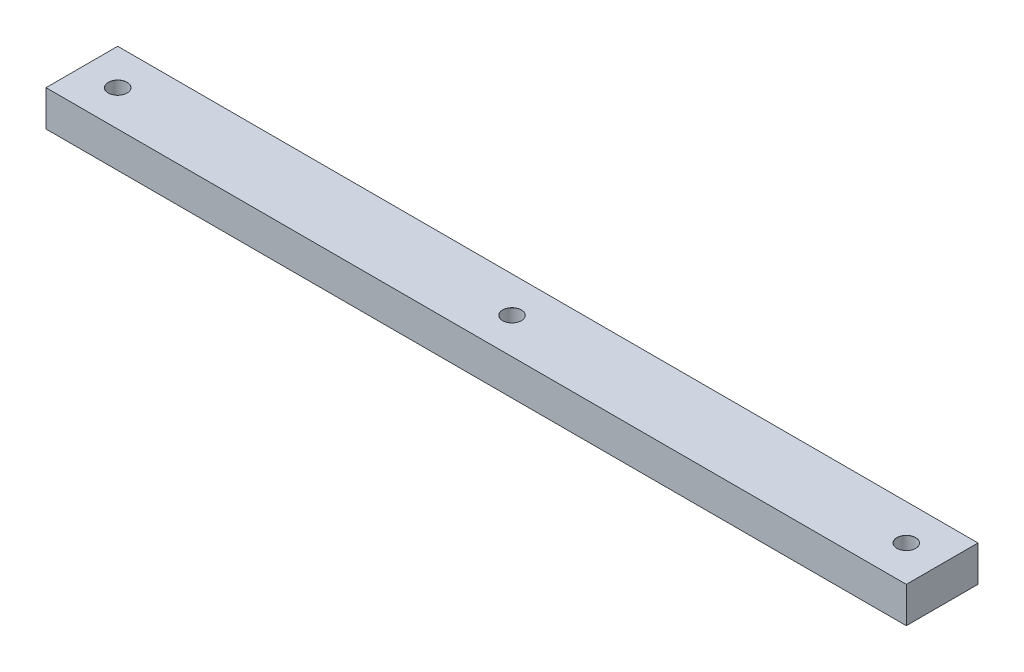
from build123d import *

# Parameters (mm, degrees)
SKETCH1_W                      = 304.8
SKETCH1_H                      = 25.4
BOSS_EXTRUDE1_DEPTH            = 12.7
M6_CLEARANCE_HOLE1_D           = 6.6
M6_CLEARANCE_HOLE1_CSINK_D     = 6.65
M6_CLEARANCE_HOLE1_CSINK_ANGLE = 90


with BuildPart() as part:
    # Sketch1 → Boss-Extrude1 (new body)
    with BuildSketch(Plane(origin=(0, 0, 0), x_dir=(1, 0, 0), z_dir=(0, 1, 0))):
        Rectangle(SKETCH1_W, SKETCH1_H)
    extrude(amount=BOSS_EXTRUDE1_DEPTH)

    # M6 Clearance Hole1 (through all)
    with Locations(Plane.ZX.offset(12.7)):
        with Locations((0, 0), (0, -139.7), (0, 139.7)):
            CounterSinkHole(M6_CLEARANCE_HOLE1_D / 2, M6_CLEARANCE_HOLE1_CSINK_D / 2, counter_sink_angle=M6_CLEARANCE_HOLE1_CSINK_ANGLE)


solid = part.part
